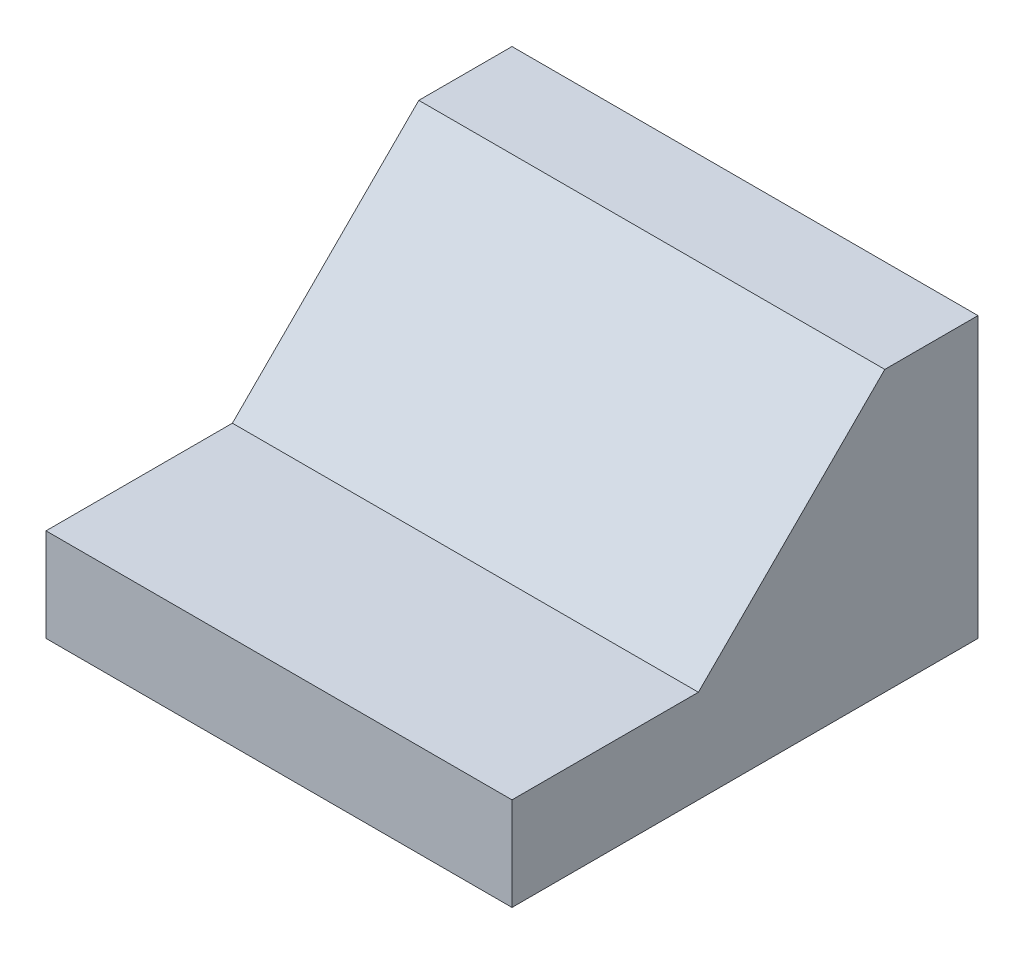
from build123d import *

# Parameters (mm, degrees)
BOSS_EXTRUDE1_DEPTH = 10


with BuildPart() as part:
    # Sketch1 → Boss-Extrude1 (new body)
    with BuildSketch(Plane(origin=(0, 0, 0), x_dir=(0, 0, -1), z_dir=(1, 0, 0))):
        Polygon((0, 0), (0, 6), (-2, 6), (-6, 2), (-10, 2), (-10, 0), align=None)
    extrude(amount=BOSS_EXTRUDE1_DEPTH)


solid = part.part
